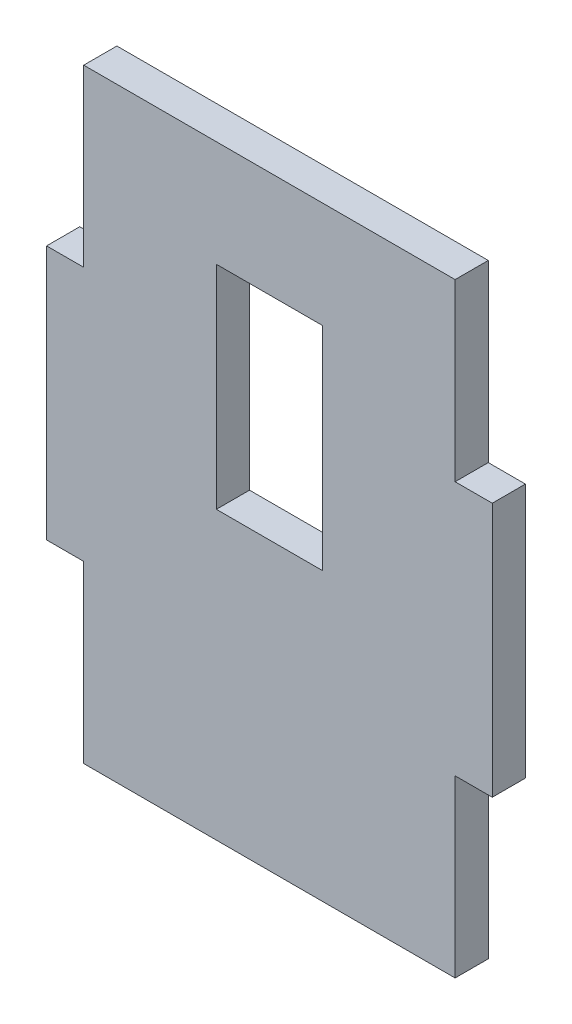
from build123d import *

# Parameters (mm, degrees)
SKETCH1_W           = 336
SKETCH1_H           = 456
BOSS_EXTRUDE1_DEPTH = 25
SKETCH3_W           = 28
SKETCH3_H           = 132
CUT_EXTRUDE1_DEPTH  = 25
SKETCH4_W           = 80
SKETCH4_H           = 160
CUT_EXTRUDE2_DEPTH  = 25


with BuildPart() as part:
    # Sketch1 → Boss-Extrude1 (new body)
    with BuildSketch(Plane.XY):
        with Locations((58.220689655, 16.117241379)):
            Rectangle(SKETCH1_W, SKETCH1_H)
    extrude(amount=BOSS_EXTRUDE1_DEPTH)

    # Sketch3 → Cut-Extrude1 (cut)
    with BuildSketch(Plane.XY):
        with Locations((-95.779310345, 178.117241379)):
            Rectangle(SKETCH3_W, SKETCH3_H)
        with Locations((212.220689655, 178.117241379)):
            Rectangle(SKETCH3_W, SKETCH3_H)
        with Locations((212.220689655, -145.882758621)):
            Rectangle(SKETCH3_W, SKETCH3_H)
        with Locations((-95.779310345, -145.882758621)):
            Rectangle(SKETCH3_W, SKETCH3_H)
    extrude(amount=CUT_EXTRUDE1_DEPTH, mode=Mode.SUBTRACT)

    # Sketch4 → Cut-Extrude2 (cut)
    with BuildSketch(Plane.XY.offset(25)):
        with Locations((58.220689655, 84.117241379)):
            Rectangle(SKETCH4_W, SKETCH4_H)
    extrude(amount=-CUT_EXTRUDE2_DEPTH, mode=Mode.SUBTRACT)


solid = part.part
